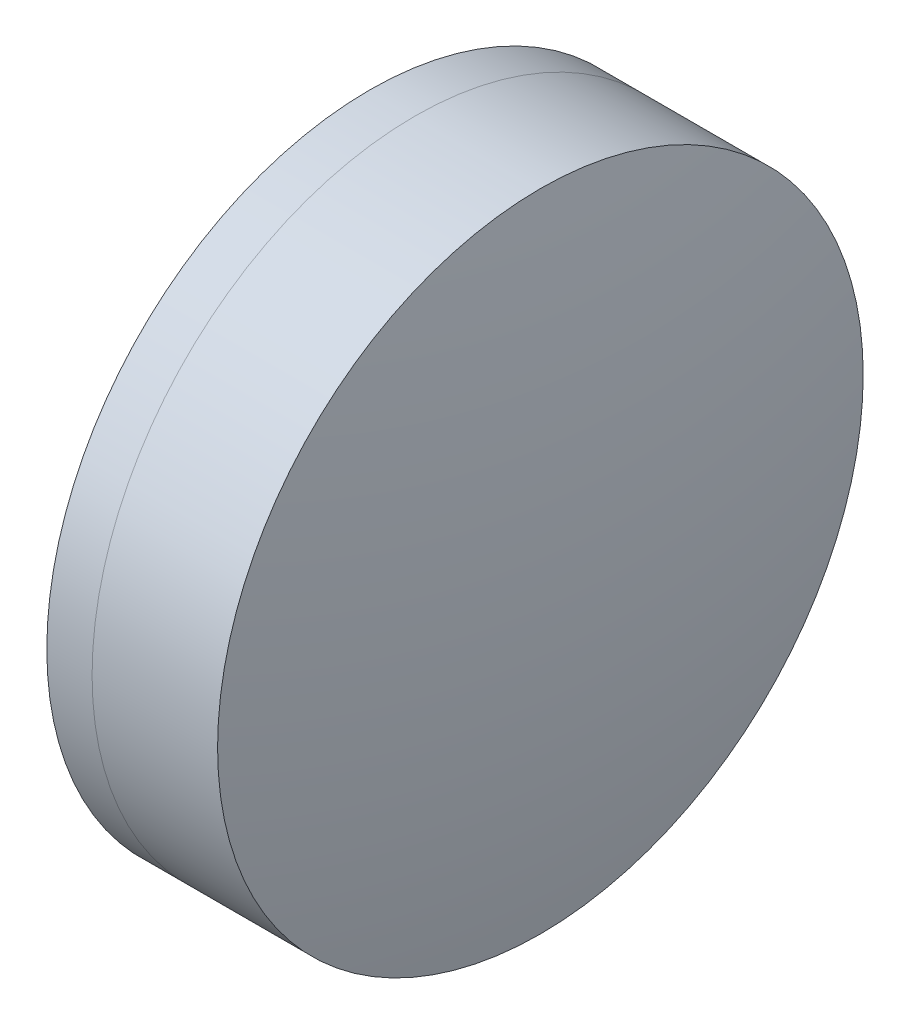
from build123d import *


with BuildPart() as part:
    # 草图1 one side → 旋转1 (revolve)
    with BuildSketch(Plane(origin=(0, 0, 0), x_dir=(1, 0, 0), z_dir=(0, 1, 0)), mode=Mode.PRIVATE) as revolve_1_sk:
        with BuildLine():
            ThreePointArc((33.169089808, 12.5), (31.323675798, 6.370696614), (30.700668974, 0))
            Line((30.700668974, 0), (38.500668974, 0))
            ThreePointArc((38.500668974, 0), (37.588427594, 6.501070907), (34.922164851, 12.5))
            Line((34.922164851, 12.5), (33.169089808, 12.5))
        make_face()
    revolve(revolve_1_sk.sketch.rotate(Axis((-9.702612178, 0, 0), (1, 0, 0)), 180), axis=Axis((-9.702612178, 0, 0), (1, 0, 0)))  # turned: the seam where the file's is


with BuildPart() as body_2:
    # 草图2 one side → 旋转3 (revolve)
    with BuildSketch(Plane(origin=(0, 0, 0), x_dir=(1, 0, 0), z_dir=(0, 1, 0)), mode=Mode.PRIVATE) as revolve_3_sk:
        with BuildLine():
            Line((39.781670557, 12.5), (34.922164851, 12.5))
            ThreePointArc((34.922164851, 12.5), (37.588427594, 6.501070907), (38.500668974, 0))
            Line((38.500668974, 0), (41.000668974, 0))
            ThreePointArc((41.000668974, 0), (40.695198243, 6.279648819), (39.781670557, 12.5))
        make_face()
    revolve(revolve_3_sk.sketch.rotate(Axis((-0.551919993, 0, 0), (1, 0, 0)), 180), axis=Axis((-0.551919993, 0, 0), (1, 0, 0)))  # turned: the seam where the file's is


solid = Compound([part.part, body_2.part])
